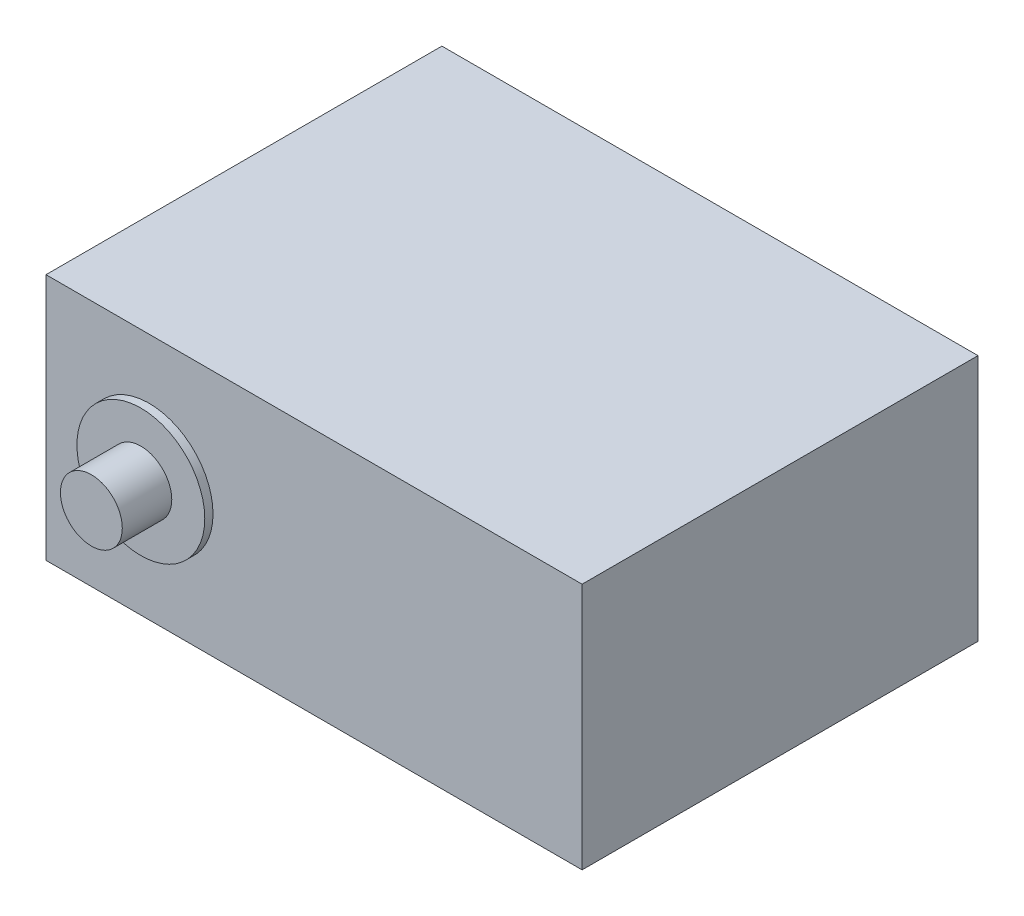
from build123d import *

# Parameters (mm, degrees)
SKETCH2_W           = 65
SKETCH2_H           = 30
BOSS_EXTRUDE1_DEPTH = 48
SKETCH3_R           = 3.75
BOSS_EXTRUDE2_DEPTH = 7
SKETCH4_R           = 7.75
BOSS_EXTRUDE3_DEPTH = 1
SKETCH5_R           = 3
BOSS_EXTRUDE6_DEPTH = 7
SKETCH7_R           = 7.75
BOSS_EXTRUDE7_DEPTH = 1
SKETCH8_W           = 4
SKETCH8_H           = 6
BOSS_EXTRUDE8_DEPTH = 5.5


with BuildPart() as part:
    # Sketch2 → Boss-Extrude1 (new body)
    with BuildSketch(Plane.XY):
        with Locations((8.357142857, 1.357142857)):
            Rectangle(SKETCH2_W, SKETCH2_H)
    extrude(amount=BOSS_EXTRUDE1_DEPTH)

    # Sketch3 → Boss-Extrude2 (add)
    with BuildSketch(Plane.XY.offset(48)):
        with Locations((-11.642857143, 1.357142857)):
            Circle(SKETCH3_R)
    extrude(amount=BOSS_EXTRUDE2_DEPTH)

    # Sketch4 → Boss-Extrude3 (add)
    with BuildSketch(Plane.XY.offset(48)):
        with Locations((-11.642857143, 1.357142857)):
            Circle(SKETCH4_R)
    extrude(amount=BOSS_EXTRUDE3_DEPTH)

    # Sketch5 → Boss-Extrude6 (add)
    with BuildSketch(Plane(origin=(0, 0, 0), x_dir=(-1, 0, 0), z_dir=(0, 0, -1))):
        with Locations((11.642857143, 1.357142857)):
            Circle(SKETCH5_R)
    extrude(amount=BOSS_EXTRUDE6_DEPTH)

    # Sketch7 → Boss-Extrude7 (add)
    with BuildSketch(Plane(origin=(0, 0, 0), x_dir=(-1, 0, 0), z_dir=(0, 0, -1))):
        with Locations((11.642857143, 1.357142857)):
            Circle(SKETCH7_R)
    extrude(amount=BOSS_EXTRUDE7_DEPTH)

    # Sketch8 → Boss-Extrude8 (add)
    with BuildSketch(Plane.ZY.offset(24.142857143)):
        with Locations((8.5, 1.357142857)):
            Rectangle(SKETCH8_W, SKETCH8_H)
    extrude(amount=BOSS_EXTRUDE8_DEPTH)


solid = part.part
